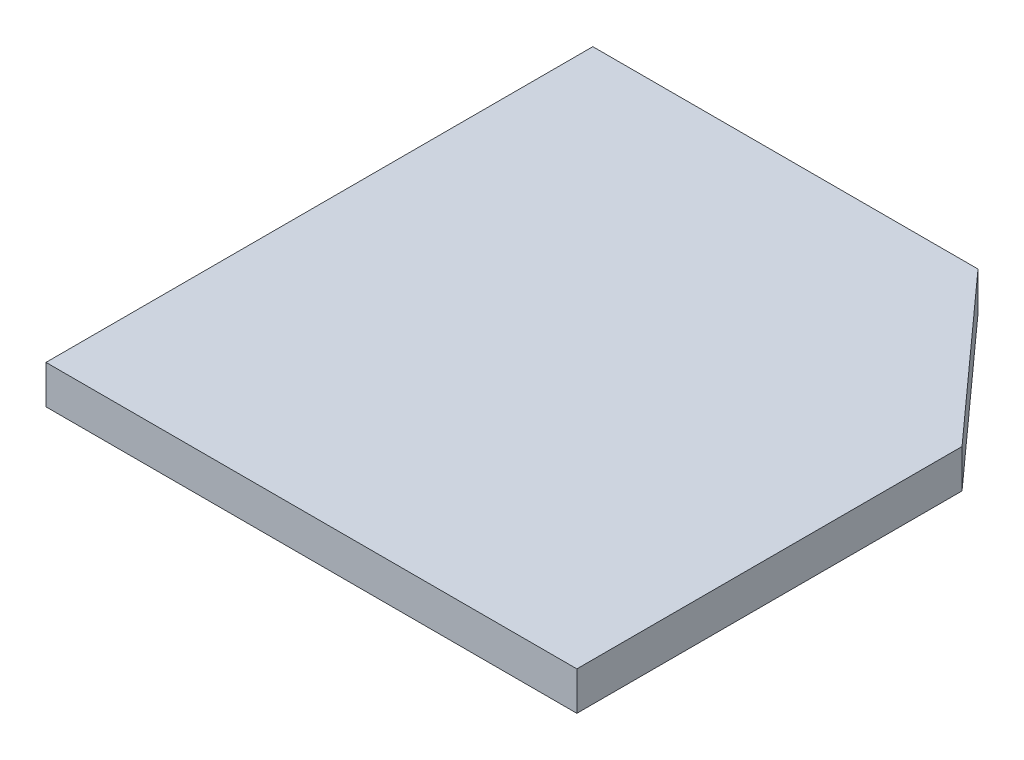
from build123d import *

# Parameters (mm, degrees)
EXTRUDE_1_DEPTH = 5


with BuildPart() as part:
    # Эскиз1 → Бобышка-Вытянуть1 (new body)
    with BuildSketch(Plane(origin=(0, 0, 0), x_dir=(1, 0, 0), z_dir=(0, 1, 0))):
        Polygon((0, 0), (68.914198713, 0), (68.914198713, 50), (50, 70.987666378), (0, 70.987666378), align=None)
    extrude(amount=EXTRUDE_1_DEPTH)


solid = part.part
